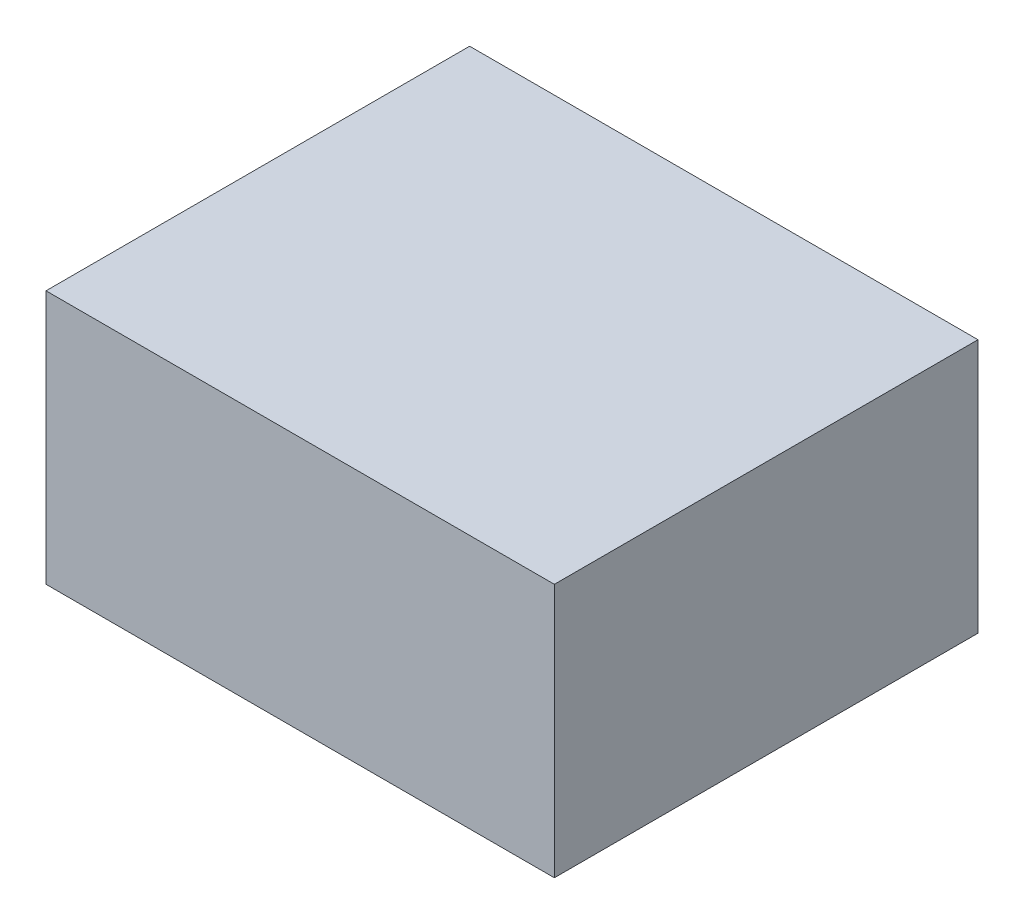
from build123d import *

# Parameters (mm, degrees)
SKETCH1_W           = 36
SKETCH1_H           = 30
BOSS_EXTRUDE1_DEPTH = 18


with BuildPart() as part:
    # Sketch1 → Boss-Extrude1 (new body)
    with BuildSketch(Plane(origin=(0, 0, 0), x_dir=(1, 0, 0), z_dir=(0, 1, 0))):
        with Locations((18, 15)):
            Rectangle(SKETCH1_W, SKETCH1_H)
    extrude(amount=BOSS_EXTRUDE1_DEPTH)


solid = part.part
